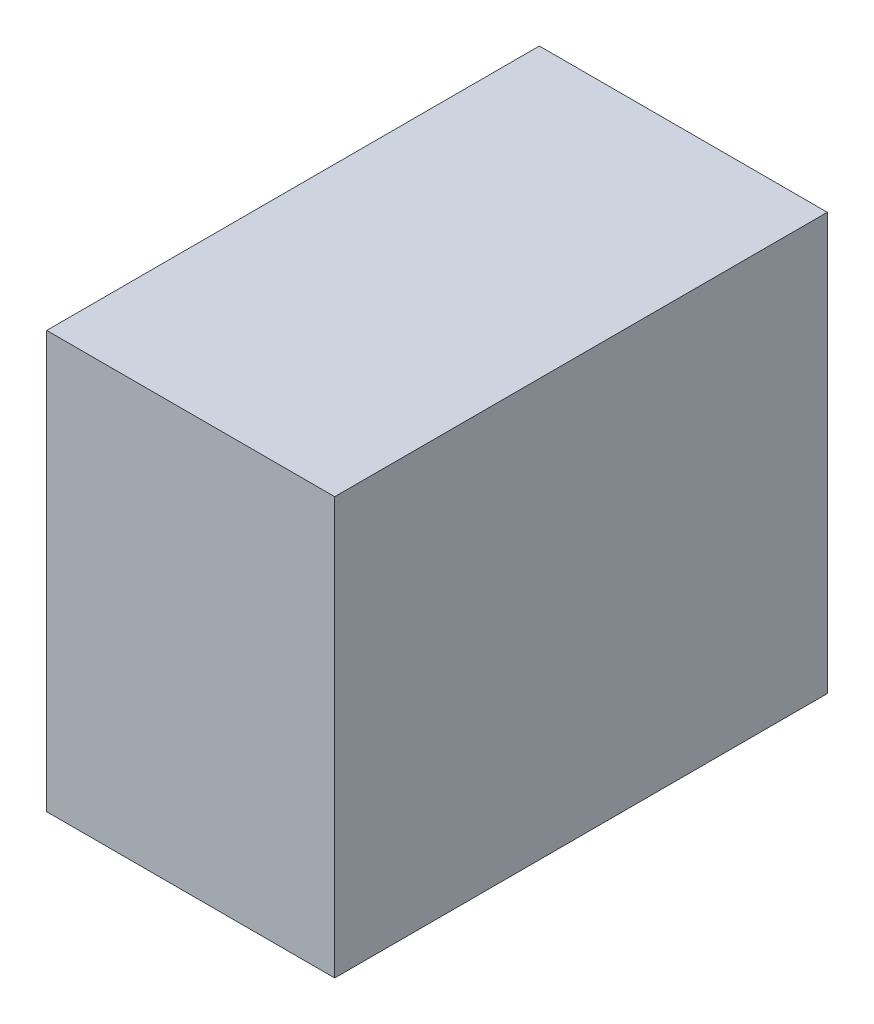
from build123d import *

# Parameters (mm, degrees)
SKETCH1_W             = 139.7
SKETCH1_H             = 165.1
BOSS_EXTRUDE4_DEPTH   = 48.26
BODY_MOVE_COPY1_ANGLE = 90


with BuildPart() as part:
    # Sketch1 → Boss-Extrude4 (new body, symmetric)
    with BuildSketch(Plane(origin=(0, 0, 0), x_dir=(1, 0, 0), z_dir=(0, 1, 0))):
        Rectangle(SKETCH1_W, SKETCH1_H)
    extrude(amount=BOSS_EXTRUDE4_DEPTH, both=True)


with BuildPart() as part_1:
    # Body-Move/Copy1: moved
    add(part.part.rotate(Axis((0, 0, 0), (0, 0, 1)), BODY_MOVE_COPY1_ANGLE))


solid = part_1.part
